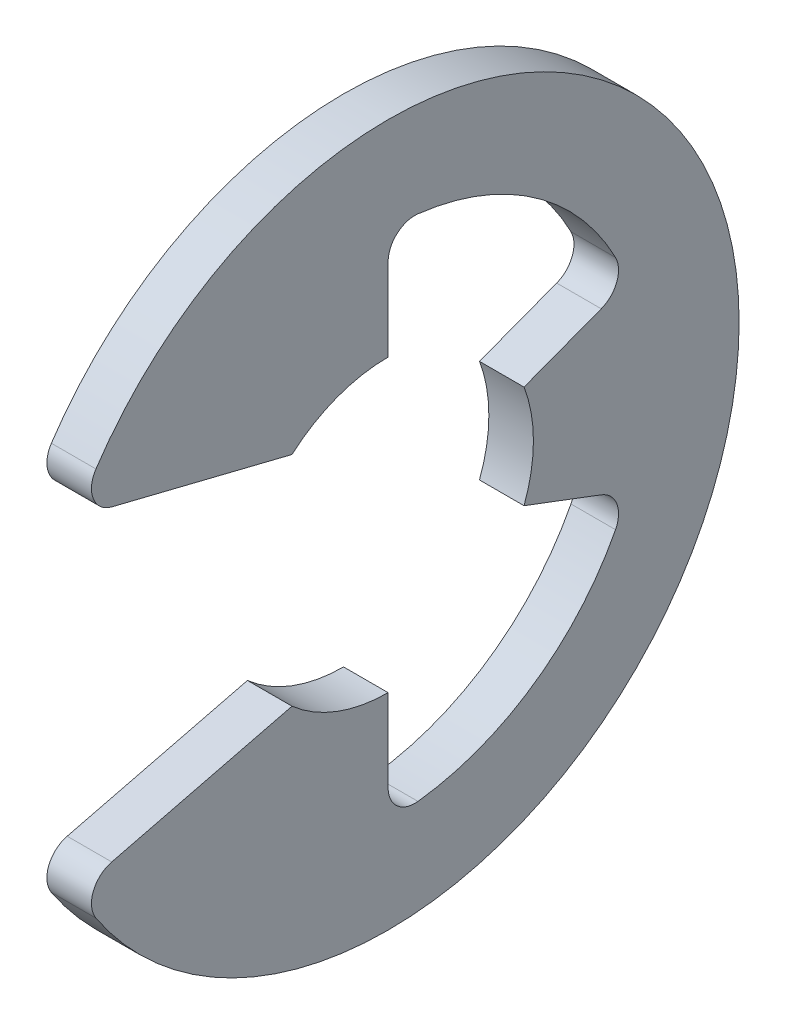
from build123d import *

# Parameters (mm, degrees)
EXTRUDE1_DEPTH = 0.5
FILLET1_R      = 0.6


with BuildPart() as part:
    # Sketch1 → Extrude1 (new body, symmetric)
    with BuildSketch(Plane(origin=(0, 0, 0), x_dir=(0, 0, -1), z_dir=(1, 0, 0))):
        with BuildLine():
            Line((-6.981705618, -3.642994877), (-2.156287319, -2.445))
            ThreePointArc((-2.156287319, -2.445), (-1.152584053, -3.04945077), (0, -3.26))
            Line((0, -3.26), (0, -5.747096774))
            ThreePointArc((0, -5.747096774), (3.267381482, -4.727931851), (5.375916774, -2.031905551))
            Line((5.375916774, -2.031905551), (3.04945077, -1.152584053))
            ThreePointArc((3.04945077, -1.152584053), (3.26, 0), (3.04945077, 1.152584053))
            Line((3.04945077, 1.152584053), (5.375916774, 2.031905551))
            ThreePointArc((5.375916774, 2.031905551), (3.267381482, 4.727931851), (0, 5.747096774))
            Line((0, 5.747096774), (0, 3.26))
            ThreePointArc((0, 3.26), (-1.152584053, 3.04945077), (-2.156287319, 2.445))
            Line((-2.156287319, 2.445), (-6.981705618, 3.642994877))
            ThreePointArc((-6.981705618, 3.642994877), (7.875, 0), (-6.981705618, -3.642994877))
        make_face()
    extrude(amount=EXTRUDE1_DEPTH, both=True)

    # Fillet1
    fillet1_edges = [part.edges().sort_by_distance(p)[0] for p in [
        (0, -3.642994877, 6.981705618),
        (0, -5.747096774, 0),
        (0, -2.031905551, -5.375916774),
        (0, 2.031905551, -5.375916774),
        (0, 5.747096774, 0),
        (0, 3.642994877, 6.981705618),
    ]]
    fillet(fillet1_edges, radius=FILLET1_R)


solid = part.part
